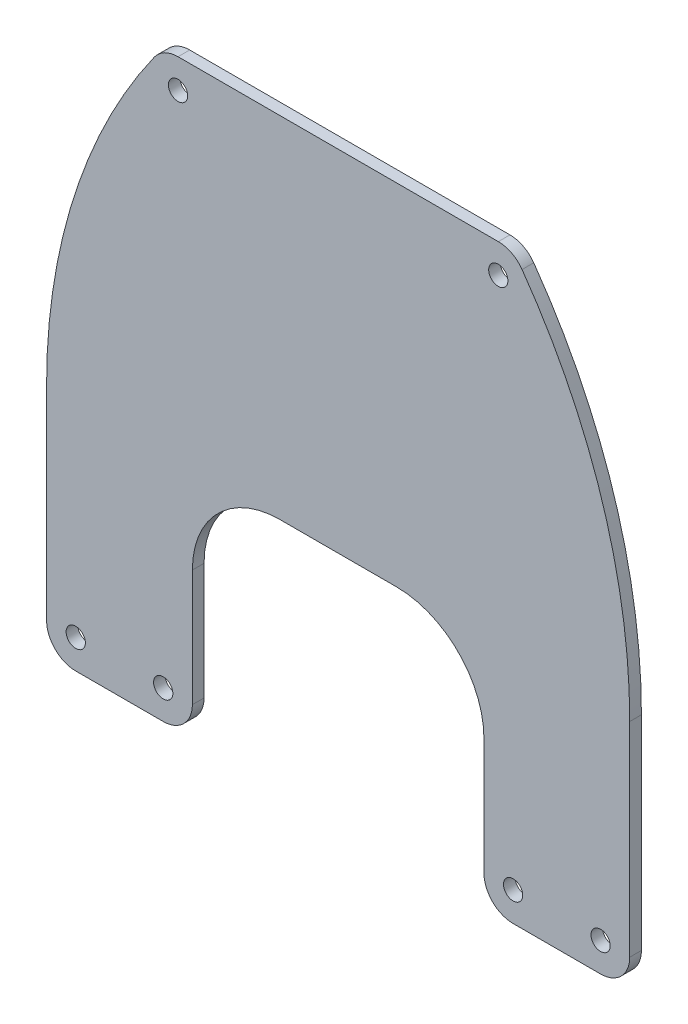
from build123d import *

# Parameters (mm, degrees)
SKETCH_1_W          = 25
SKETCH_1_H          = 40
EXTRUDE_1_DEPTH     = 2
FILLET_1_R          = 15
FILLET_2_R          = 5
FILLET_3_R          = 5
SKETCH_2_R          = 1.65
CUT_EXTRUDE_2_DEPTH = 2


with BuildPart() as part:
    # 草图1 → 凸台-拉伸1 (new body)
    with BuildSketch(Plane.XY):
        with BuildLine():
            Line((-25, 40), (0, 40))
            ThreePointArc((0, 40), (-5.131670195, 71.622776602), (-20, 100))
            Line((-20, 100), (-80, 100))
            ThreePointArc((-80, 100), (-94.868329805, 71.622776602), (-100, 40))
            Line((-100, 40), (-75, 40))
            Line((-75, 40), (-25, 40))
        make_face()
        with Locations((-87.5, 20)):
            Rectangle(SKETCH_1_W, SKETCH_1_H)
        with Locations((-12.5, 20)):
            Rectangle(SKETCH_1_W, SKETCH_1_H)
    extrude(amount=EXTRUDE_1_DEPTH)

    # 圆角1
    fillet_1_edges = [part.edges().sort_by_distance(p)[0] for p in [
        (-75, 40, 1),
        (-25, 40, 1),
    ]]
    fillet(fillet_1_edges, radius=FILLET_1_R)

    # 圆角2
    fillet_2_edges = [part.edges().sort_by_distance(p)[0] for p in [
        (-75, 0, 1),
        (-100, 0, 1),
        (0, 0, 1),
        (-25, 0, 1),
    ]]
    fillet(fillet_2_edges, radius=FILLET_2_R)

    # 圆角3
    fillet_3_edges = [part.edges().sort_by_distance(p)[0] for p in [
        (-80, 100, 1),
        (-20, 100, 1),
    ]]
    fillet(fillet_3_edges, radius=FILLET_3_R)

    # 草图2 → 切除-拉伸2 (cut)
    with BuildSketch(Plane.XY.offset(2)):
        with Locations((-77.459666924, 95)):
            Circle(SKETCH_2_R)
        with Locations((-22.540333076, 95)):
            Circle(SKETCH_2_R)
        with Locations((-95, 5)):
            Circle(SKETCH_2_R)
        with Locations((-5, 5)):
            Circle(SKETCH_2_R)
        with Locations((-80, 5)):
            Circle(SKETCH_2_R)
        with Locations((-20, 5)):
            Circle(SKETCH_2_R)
    extrude(amount=-CUT_EXTRUDE_2_DEPTH, mode=Mode.SUBTRACT)


solid = part.part
